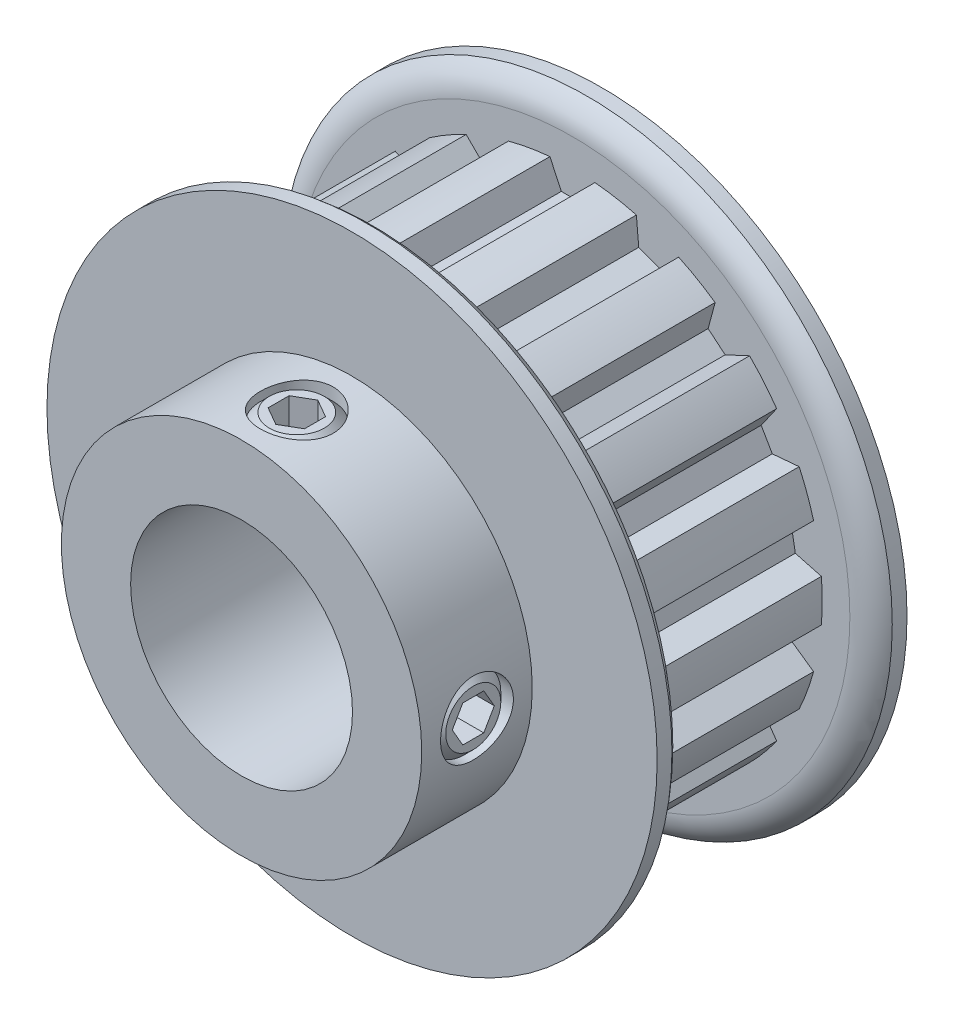
from build123d import *

# Parameters (mm, degrees)
CUT_EXTRUDE1_START = 2.2987
CUT_EXTRUDE1_DEPTH = 10.922
CIRPATTERN1_COUNT  = 18
SKETCH4_R          = 2.0828
CUT_EXTRUDE2_DEPTH = 27.762350537
CUT_EXTRUDE3_DEPTH = 1.5621
CIRPATTERN2_COUNT  = 2
CIRPATTERN2_ANGLE  = 90


with BuildPart() as part:
    # Sketch2 → Revolve1 (revolve)
    with BuildSketch(Plane(origin=(0, 0, 0), x_dir=(0, 0, -1), z_dir=(1, 0, 0)), mode=Mode.PRIVATE) as revolve1_sk:
        with BuildLine():
            Line((-10.3124, 6.35), (10.3124, 6.35))
            Line((10.3124, 6.35), (10.3124, 17.4625))
            Line((10.3124, 17.4625), (9.46785, 17.4625))
            ThreePointArc((9.46785, 17.4625), (8.847668679, 16.777633999), (8.6233, 15.88135))
            Line((8.6233, 15.88135), (8.6233, 14.3002))
            Line((8.6233, 14.3002), (-2.2987, 14.3002))
            Line((-2.2987, 14.3002), (-2.2987, 15.88135))
            ThreePointArc((-2.2987, 15.88135), (-2.523068679, 16.777633999), (-3.14325, 17.4625))
            Line((-3.14325, 17.4625), (-3.9878, 17.4625))
            Line((-3.9878, 17.4625), (-3.9878, 10.3124))
            Line((-3.9878, 10.3124), (-10.3124, 10.3124))
            Line((-10.3124, 10.3124), (-10.3124, 6.35))
        make_face()
    revolve(revolve1_sk.sketch.rotate(Axis((0, 0, 10.3124), (0, 0, -1)), 90), axis=Axis((0, 0, 10.3124), (0, 0, -1)))

    # Sketch3 → Cut-Extrude1 (cut)
    with BuildSketch(Plane.XY.offset(CUT_EXTRUDE1_START)):
        with BuildLine():
            Line((-0.635, 12.842092967), (0.635, 12.842092967))
            Line((0.635, 12.842092967), (1.287830721, 14.242092967))
            ThreePointArc((1.287830721, 14.242092967), (0, 14.3002), (-1.287830721, 14.242092967))
            Line((-1.287830721, 14.242092967), (-0.635, 12.842092967))
        make_face()
    cut_extrude1 = extrude(amount=-CUT_EXTRUDE1_DEPTH, mode=Mode.SUBTRACT)

    # CirPattern1: Cut-Extrude1 ×18 about axis
    cirpattern1_axis = Axis((0, 0, 0), (0, 0, 1))
    for i in range(1, CIRPATTERN1_COUNT):
        add(cut_extrude1.rotate(cirpattern1_axis, i * 360 / CIRPATTERN1_COUNT), mode=Mode.SUBTRACT)

    # Sketch4 → Cut-Extrude2 (cut, through all)
    with BuildSketch(Plane(origin=(0, 0, 0), x_dir=(1, 0, 0), z_dir=(0, 1, 0))):
        with Locations(Location((0, -7.1501, 0), (0, 0, 90))):
            Circle(SKETCH4_R)
    cut_extrude2 = extrude(amount=CUT_EXTRUDE2_DEPTH, mode=Mode.SUBTRACT)

    # Sketch5 → Revolve2 (revolve)
    with BuildSketch(Plane.XY.offset(7.1501), mode=Mode.PRIVATE) as revolve2_sk:
        Polygon((1.5748, 10.099878114), (2.0828, 9.591878114), (2.0828, 6.985), (1.4478, 6.35), (0, 6.35), (0, 10.099878114), align=None)
    revolve2 = revolve(revolve2_sk.sketch.rotate(Axis((0, 0, 7.1501), (0, 1, 0)), 90), axis=Axis((0, 0, 7.1501), (0, 1, 0)))

    # Sketch6 → Cut-Extrude3 (cut)
    with BuildSketch(Plane(origin=(0, 10.099878114, 0), x_dir=(1, 0, 0), z_dir=(0, 1, 0))):
        Polygon((0, -5.947594859), (-1.0414, -6.54884743), (-1.0414, -7.75135257), (0, -8.352605141), (1.0414, -7.75135257), (1.0414, -6.54884743), align=None)
    cut_extrude3 = extrude(amount=-CUT_EXTRUDE3_DEPTH, mode=Mode.SUBTRACT)

    # CirPattern2: Cut-Extrude2, Revolve2, Cut-Extrude3 ×2 about axis
    cirpattern2_axis = Axis((0, 0, 0), (0, 0, -1))
    add([cut_extrude2.rotate(cirpattern2_axis, i * CIRPATTERN2_ANGLE / (CIRPATTERN2_COUNT - 1)) for i in range(1, CIRPATTERN2_COUNT)], mode=Mode.SUBTRACT)
    add([revolve2.rotate(cirpattern2_axis, i * CIRPATTERN2_ANGLE / (CIRPATTERN2_COUNT - 1)) for i in range(1, CIRPATTERN2_COUNT)])
    add([cut_extrude3.rotate(cirpattern2_axis, i * CIRPATTERN2_ANGLE / (CIRPATTERN2_COUNT - 1)) for i in range(1, CIRPATTERN2_COUNT)], mode=Mode.SUBTRACT)


solid = part.part
